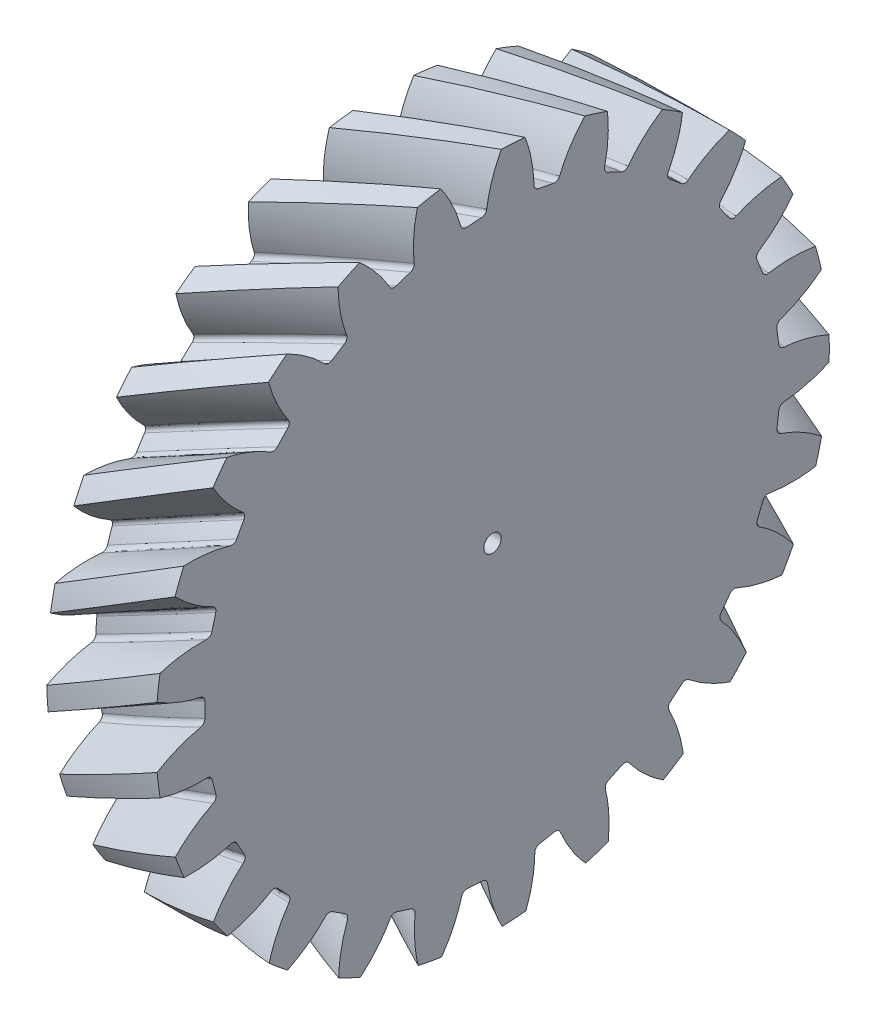
from build123d import *

# Parameters (mm, degrees)
BASPROSKE_W            = 5
BASPROSKE_H            = 15.43375673
TOOTHCUTLH_PITCH       = 167.962428865
TOOTHCUTLH_HEIGHT      = 5
TOOTHCUTLH_RADIUS      = 15.43375673
TOOTHCUTLH_START_ANGLE = -90
TEETHCUTSLH_COUNT      = 25
TEETHCUTSLH_ANGLE      = 345.6
BORSKE_R               = 0.4
BORE_DEPTH             = 62.5000025


with BuildPart() as part:
    # BasProSke → Base-Revolve (revolve)
    with BuildSketch(Plane(origin=(0, 0, 0), x_dir=(1, 0, 0), z_dir=(0, 1, 0)), mode=Mode.PRIVATE) as base_revolve_sk:
        with Locations((2.5, 7.716878365)):
            Rectangle(BASPROSKE_W, BASPROSKE_H)
    revolve(base_revolve_sk.sketch.rotate(Axis((-10, 0, 0), (1, 0, 0)), 180), axis=Axis((-10, 0, 0), (1, 0, 0)))

    # ToothCutLH: sweep along a helix
    with BuildLine() as toothcutlh_path:
        add(Helix(TOOTHCUTLH_PITCH, TOOTHCUTLH_HEIGHT, TOOTHCUTLH_RADIUS, center=(0, 0, 0), direction=(1, 0, 0), lefthand=True, mode=Mode.PRIVATE).rotate(Axis((0, 0, 0), (1, 0, 0)), TOOTHCUTLH_START_ANGLE))
    # TooCutSkeRH_3 → ToothCutLH (sweep, cut)
    with BuildSketch(Plane(origin=(0, 0, 0), x_dir=(0, 0, -1), z_dir=(1, 0, 0))):
        with BuildLine():
            ThreePointArc((0.343578704, 13.179279008), (0, 13.18375673), (-0.343578704, 13.179279008))
            ThreePointArc((-0.343578704, 13.179279008), (-0.505737768, 13.233256977), (-0.595747672, 13.378540838))
            ThreePointArc((-0.595747672, 13.378540838), (-1.00995007, 14.651542794), (-1.685748282, 15.807135449))
            ThreePointArc((-1.685748282, 15.807135449), (0, 15.896769432), (1.685748282, 15.807135449))
            ThreePointArc((1.685748282, 15.807135449), (1.00995007, 14.651542794), (0.595747672, 13.378540838))
            ThreePointArc((0.595747672, 13.378540838), (0.505737768, 13.233256977), (0.343578704, 13.179279008))
        make_face()
    toothcutlh = sweep(path=toothcutlh_path.line, is_frenet=True, mode=Mode.SUBTRACT)

    # TeethCutsLH: ToothCutLH ×25 about axis
    teethcutslh_axis = Axis((-10, 0, 0), (1, 0, 0))
    for i in range(1, TEETHCUTSLH_COUNT):
        add(toothcutlh.rotate(teethcutslh_axis, i * TEETHCUTSLH_ANGLE / (TEETHCUTSLH_COUNT - 1)), mode=Mode.SUBTRACT)

    # BorSke → Bore (cut, symmetric)
    with BuildSketch(Plane(origin=(0, 0, 0), x_dir=(0, 0, -1), z_dir=(1, 0, 0))):
        with Locations(Location((0, 0, 0), (0, 0, 180))):
            Circle(BORSKE_R)
    extrude(amount=BORE_DEPTH, both=True, mode=Mode.SUBTRACT)


solid = part.part
